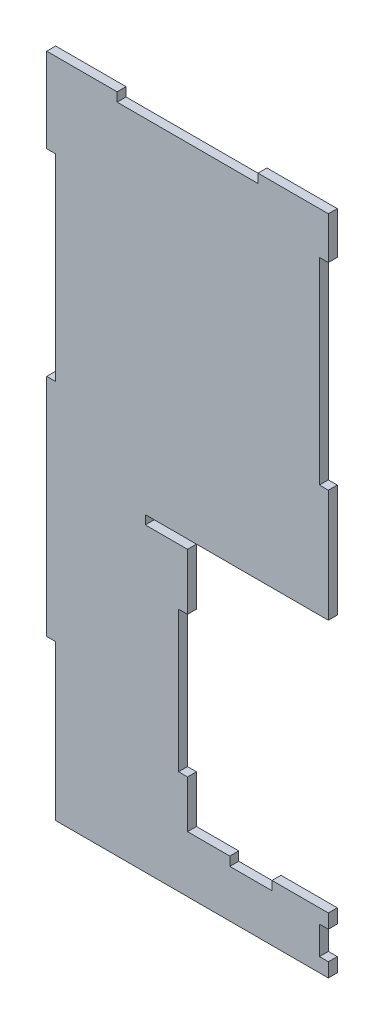
from build123d import *

# Parameters (mm, degrees)
BOSS_EXTRUDE1_DEPTH = 3.175
SKETCH2_W           = 15
SKETCH2_H           = 3.175
CUT_EXTRUDE1_DEPTH  = 10
SKETCH3_W           = 50
SKETCH3_H           = 3.175
CUT_EXTRUDE2_DEPTH  = 10
SKETCH4_W           = 3.175
SKETCH4_H           = 10
CUT_EXTRUDE3_DEPTH  = 10


with BuildPart() as part:
    # Sketch1 → Boss-Extrude1 (new body)
    with BuildSketch(Plane.XY):
        Polygon((3.175, 0), (3.175, 55), (0, 55), (0, 135), (3.175, 135), (3.175, 205), (0, 205), (0, 235), (100, 235), (100, 220), (96.825, 220), (96.825, 150), (100, 150), (100, 110), (50, 110), (35, 110), (35, 106.825), (50, 106.825), (50, 86.825), (46.825, 86.825), (46.825, 36.825), (50, 36.825), (50, 20), (100, 20), (100, 0), align=None)
    extrude(amount=-BOSS_EXTRUDE1_DEPTH)

    # Sketch2 → Cut-Extrude1 (cut)
    with BuildSketch(Plane.XY):
        with Locations((72.5, 18.4125)):
            Rectangle(SKETCH2_W, SKETCH2_H)
    extrude(amount=-CUT_EXTRUDE1_DEPTH, mode=Mode.SUBTRACT)

    # Sketch3 → Cut-Extrude2 (cut)
    with BuildSketch(Plane.XY):
        with Locations((50, 233.4125)):
            Rectangle(SKETCH3_W, SKETCH3_H)
    extrude(amount=-CUT_EXTRUDE2_DEPTH, mode=Mode.SUBTRACT)

    # Sketch4 → Cut-Extrude3 (cut)
    with BuildSketch(Plane.XY):
        with Locations((98.4125, 10)):
            Rectangle(SKETCH4_W, SKETCH4_H)
    extrude(amount=-CUT_EXTRUDE3_DEPTH, mode=Mode.SUBTRACT)


solid = part.part
